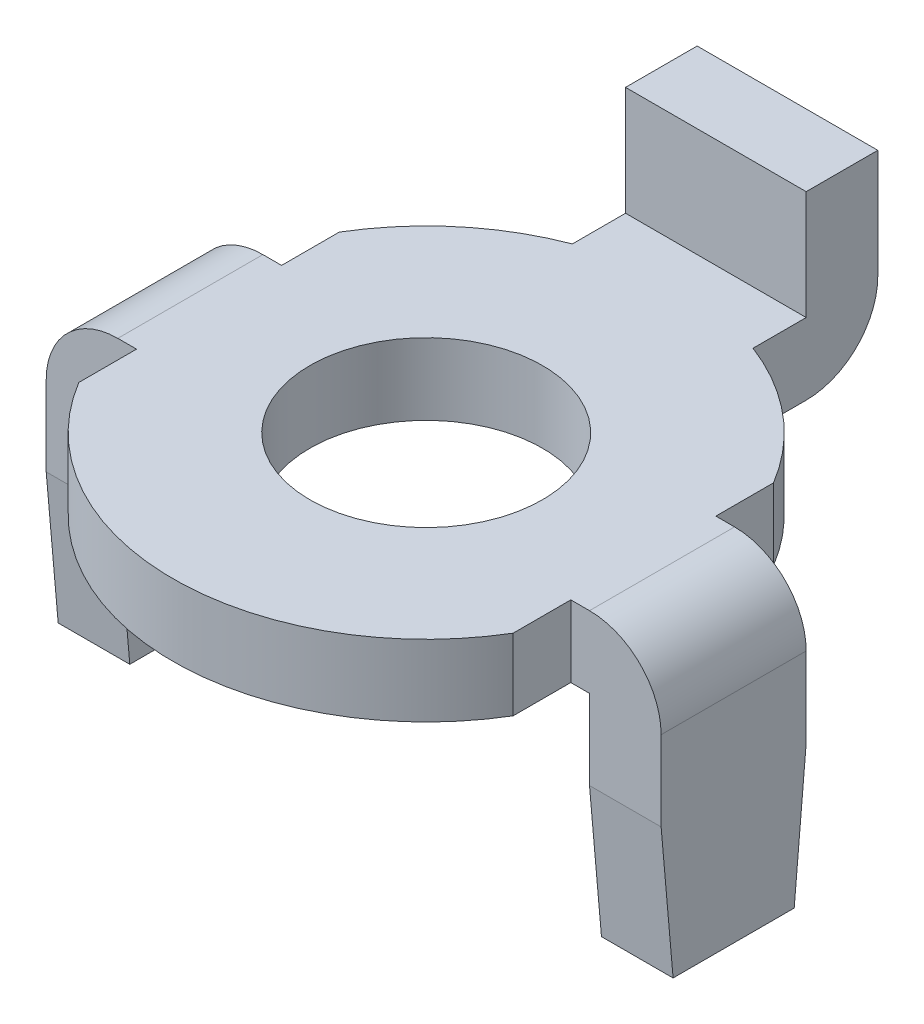
from build123d import *

# Parameters (mm, degrees)
SKETCH1_R             = 2.55
BOSS_EXTRUDE1_DEPTH   = 1.57
SKETCH2_W             = 1.57
SKETCH2_H             = 3.18
BOSS_EXTRUDE2_DEPTH   = 4.75
SKETCH3_W             = 3.96
SKETCH3_H             = 1.57
BOSS_EXTRUDE3_DEPTH   = 2.39
FILLET1_R             = 1.57
CHAMFER1_SIZE         = 3
CHAMFER1_SIZE2        = 0.262465991
CHAMFER1_PART_2_SIZE  = 3
CHAMFER1_PART_2_SIZE2 = 0.262465991
CHAMFER1_PART_3_SIZE  = 3
CHAMFER1_PART_3_SIZE2 = 0.262465991
CHAMFER1_PART_4_SIZE  = 3
CHAMFER1_PART_4_SIZE2 = 0.262465991


with BuildPart() as part:
    # Sketch1 → Boss-Extrude1 (new body)
    with BuildSketch(Plane(origin=(0, 0, 0), x_dir=(1, 0, 0), z_dir=(0, 1, 0))):
        with BuildLine():
            Line((-4.76, 2.853927119), (-4.76, 1.59))
            Line((-4.76, 1.59), (-6.74, 1.59))
            Line((-6.74, 1.59), (-6.74, -1.59))
            Line((-6.74, -1.59), (-4.76, -1.59))
            Line((-4.76, -1.59), (-4.76, -2.853927119))
            ThreePointArc((-4.76, -2.853927119), (0, -5.55), (4.76, -2.853927119))
            Line((4.76, -2.853927119), (4.76, -1.59))
            Line((4.76, -1.59), (6.74, -1.59))
            Line((6.74, -1.59), (6.74, 1.59))
            Line((6.74, 1.59), (4.76, 1.59))
            Line((4.76, 1.59), (4.76, 2.853927119))
            ThreePointArc((4.76, 2.853927119), (3.565828986, 4.252924128), (1.98, 5.184795078))
            Line((1.98, 5.184795078), (1.98, 7.92))
            Line((1.98, 7.92), (-1.98, 7.92))
            Line((-1.98, 7.92), (-1.98, 5.184795078))
            ThreePointArc((-1.98, 5.184795078), (-3.565828986, 4.252924128), (-4.76, 2.853927119))
        make_face()
        Circle(SKETCH1_R, mode=Mode.SUBTRACT)
    extrude(amount=BOSS_EXTRUDE1_DEPTH)

    # Sketch2 → Boss-Extrude2 (add)
    with BuildSketch(Plane.XZ):
        with Locations((-5.955, 0)):
            Rectangle(SKETCH2_W, SKETCH2_H)
        with Locations((5.955, 0)):
            Rectangle(SKETCH2_W, SKETCH2_H)
    extrude(amount=BOSS_EXTRUDE2_DEPTH)

    # Sketch3 → Boss-Extrude3 (add)
    with BuildSketch(Plane(origin=(0, 1.57, 0), x_dir=(1, 0, 0), z_dir=(0, 1, 0))):
        with Locations((0, 7.135)):
            Rectangle(SKETCH3_W, SKETCH3_H)
    extrude(amount=BOSS_EXTRUDE3_DEPTH)

    # Fillet1
    fillet1_edges = [part.edges().sort_by_distance(p)[0] for p in [
        (0, 0, -7.92),
        (6.74, 1.57, 0),
        (-6.74, 1.57, 0),
    ]]
    fillet(fillet1_edges, radius=FILLET1_R)

    # Chamfer1
    chamfer1_edges = [part.edges().sort_by_distance(p)[0] for p in [
        (5.955, -4.75, -1.59),
    ]]
    chamfer1_side = [part.faces().sort_by_distance(p)[0] for p in [
        (5.8686205, -1.585741835, -1.59),
    ]]
    chamfer(chamfer1_edges, length=CHAMFER1_SIZE, length2=CHAMFER1_SIZE2, reference=chamfer1_side[0])

    # Chamfer1 part 2
    chamfer1_part_2_edges = [part.edges().sort_by_distance(p)[0] for p in [
        (5.955, -4.75, 1.59),
    ]]
    chamfer1_part_2_side = [part.faces().sort_by_distance(p)[0] for p in [
        (5.8686205, -1.585741835, 1.59),
    ]]
    chamfer(chamfer1_part_2_edges, length=CHAMFER1_PART_2_SIZE, length2=CHAMFER1_PART_2_SIZE2, reference=chamfer1_part_2_side[0])

    # Chamfer1 part 3
    chamfer1_part_3_edges = [part.edges().sort_by_distance(p)[0] for p in [
        (-5.955, -4.75, -1.59),
    ]]
    chamfer1_part_3_side = [part.faces().sort_by_distance(p)[0] for p in [
        (-5.8686205, -1.585741835, -1.59),
    ]]
    chamfer(chamfer1_part_3_edges, length=CHAMFER1_PART_3_SIZE, length2=CHAMFER1_PART_3_SIZE2, reference=chamfer1_part_3_side[0])

    # Chamfer1 part 4
    chamfer1_part_4_edges = [part.edges().sort_by_distance(p)[0] for p in [
        (-5.955, -4.75, 1.59),
    ]]
    chamfer1_part_4_side = [part.faces().sort_by_distance(p)[0] for p in [
        (-5.8686205, -1.585741835, 1.59),
    ]]
    chamfer(chamfer1_part_4_edges, length=CHAMFER1_PART_4_SIZE, length2=CHAMFER1_PART_4_SIZE2, reference=chamfer1_part_4_side[0])


solid = part.part
